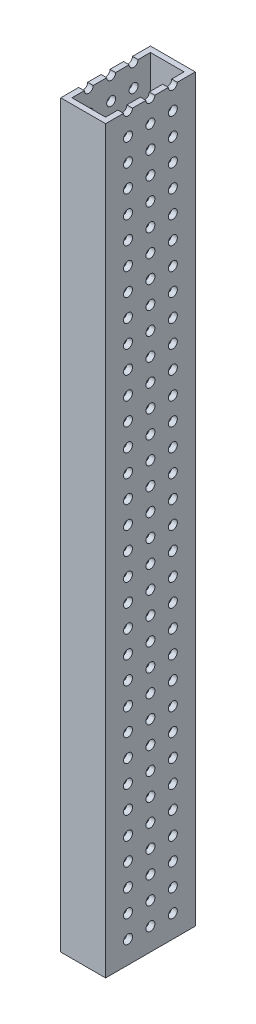
from build123d import *

# Parameters (mm, degrees)
SKETCH1_W            = 25.4
SKETCH1_H            = 50.8
SKETCH1_W_2          = 19.05
SKETCH1_H_2          = 44.45
BOSS_EXTRUDE1_DEPTH  = 419.1
SKETCH2_R            = 2.54
CUT_EXTRUDE1_DEPTH   = 423.930975456
LPATTERN1_COUNT      = 33
LPATTERN1_PITCH      = 12.7
LPATTERN1_COUNT_DIR2 = 3
LPATTERN1_PITCH_DIR2 = 12.7


with BuildPart() as part:
    # Sketch1 → Boss-Extrude1 (new body)
    with BuildSketch(Plane(origin=(0, 0, 0), x_dir=(1, 0, 0), z_dir=(0, 1, 0))):
        with Locations((50.8, 25.4)):
            Rectangle(SKETCH1_W, SKETCH1_H)
        with Locations((50.8, 25.4)):
            Rectangle(SKETCH1_W_2, SKETCH1_H_2, mode=Mode.SUBTRACT)
    extrude(amount=BOSS_EXTRUDE1_DEPTH)

    # Sketch2 → Cut-Extrude1 (cut, through all)
    with BuildSketch(Plane(origin=(63.5, 0, 0), x_dir=(0, 0, -1), z_dir=(1, 0, 0))):
        with Locations((12.7, 12.7)):
            Circle(SKETCH2_R)
    cut_extrude1 = extrude(amount=-CUT_EXTRUDE1_DEPTH, mode=Mode.SUBTRACT)

    # LPattern1: Cut-Extrude1 33 × 3
    with Locations(*[(0, i * LPATTERN1_PITCH, -j * LPATTERN1_PITCH_DIR2) for i in range(LPATTERN1_COUNT) for j in range(LPATTERN1_COUNT_DIR2) if (i, j) != (0, 0)]):
        add(cut_extrude1, mode=Mode.SUBTRACT)


solid = part.part
